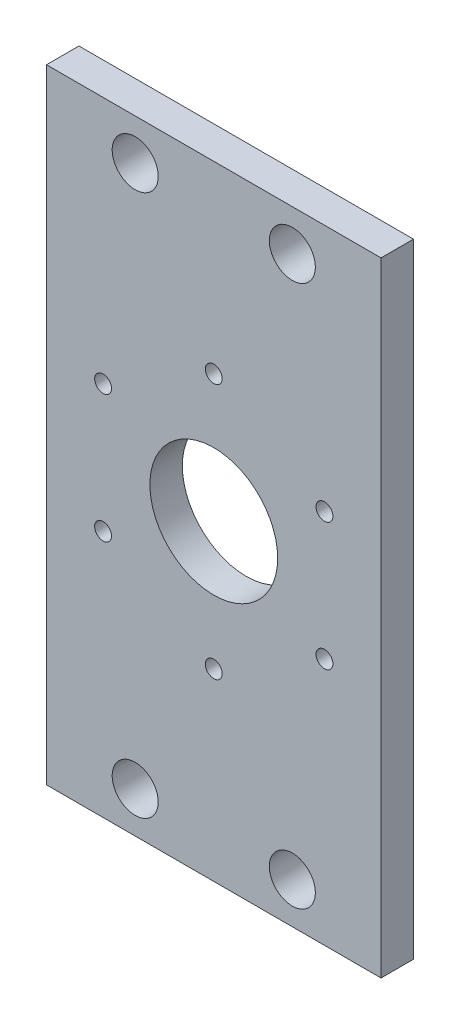
from build123d import *

# Parameters (mm, degrees)
SKETCH1_W                 = 65.44
SKETCH1_H                 = 122
BOSS_EXTRUDE1_DEPTH       = 6.35
M4X0_7_TAPPED_HOLE1_D     = 3.3
M4X0_7_TAPPED_HOLE1_DEPTH = 6.35
M8_CLEARANCE_HOLE1_D      = 9
M8_CLEARANCE_HOLE1_DEPTH  = 6.35
CUT_EXTRUDE2_REACH        = 8.35
SKETCH14_R                = 12.5


with BuildPart() as part:
    # Sketch1 → Boss-Extrude1 (new body)
    with BuildSketch(Plane.XY):
        Rectangle(SKETCH1_W, SKETCH1_H)
    extrude(amount=BOSS_EXTRUDE1_DEPTH)

    # M4x0.7 Tapped Hole1
    with Locations(Plane.XY.offset(6.35)):
        with Locations((0, 25), (-21.650635095, 12.5), (-21.650635095, -12.5), (0, -25), (21.650635095, -12.5), (21.650635095, 12.5)):
            Hole(M4X0_7_TAPPED_HOLE1_D / 2, depth=M4X0_7_TAPPED_HOLE1_DEPTH)

    # M8 Clearance Hole1
    with Locations(Plane.XY.offset(6.35)):
        with Locations((-15.37, 53), (15.37, 53), (15.37, -53), (-15.37, -53)):
            Hole(M8_CLEARANCE_HOLE1_D / 2, depth=M8_CLEARANCE_HOLE1_DEPTH)

    # Sketch14 → Cut-Extrude2 (cut, up to next)
    with BuildSketch(Plane.XY.offset(6.35), mode=Mode.PRIVATE) as cut_extrude2_sk1:
        Circle(SKETCH14_R)
    cut_extrude2_tool1 = extrude(cut_extrude2_sk1.sketch, amount=-CUT_EXTRUDE2_REACH, mode=Mode.PRIVATE) & part.part
    add(cut_extrude2_tool1.solids().sort_by_distance((0, 0, 6.35))[0], mode=Mode.SUBTRACT)


solid = part.part
